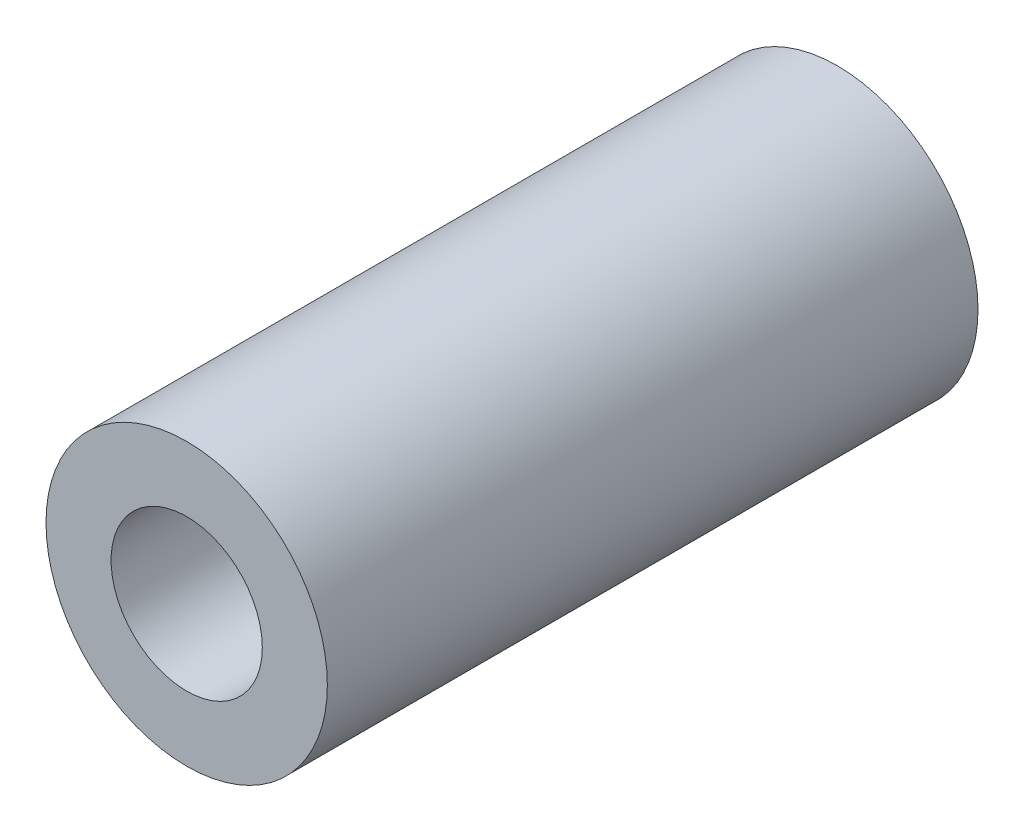
from build123d import *

# Parameters (mm, degrees)
SKETCH1_R           = 4
SKETCH1_R_2         = 2.15
BOSS_EXTRUDE1_DEPTH = 18.5


with BuildPart() as part:
    # Sketch1 → Boss-Extrude1 (new body)
    with BuildSketch(Plane.XY):
        Circle(SKETCH1_R)
        Circle(SKETCH1_R_2, mode=Mode.SUBTRACT)
    extrude(amount=BOSS_EXTRUDE1_DEPTH)


solid = part.part
